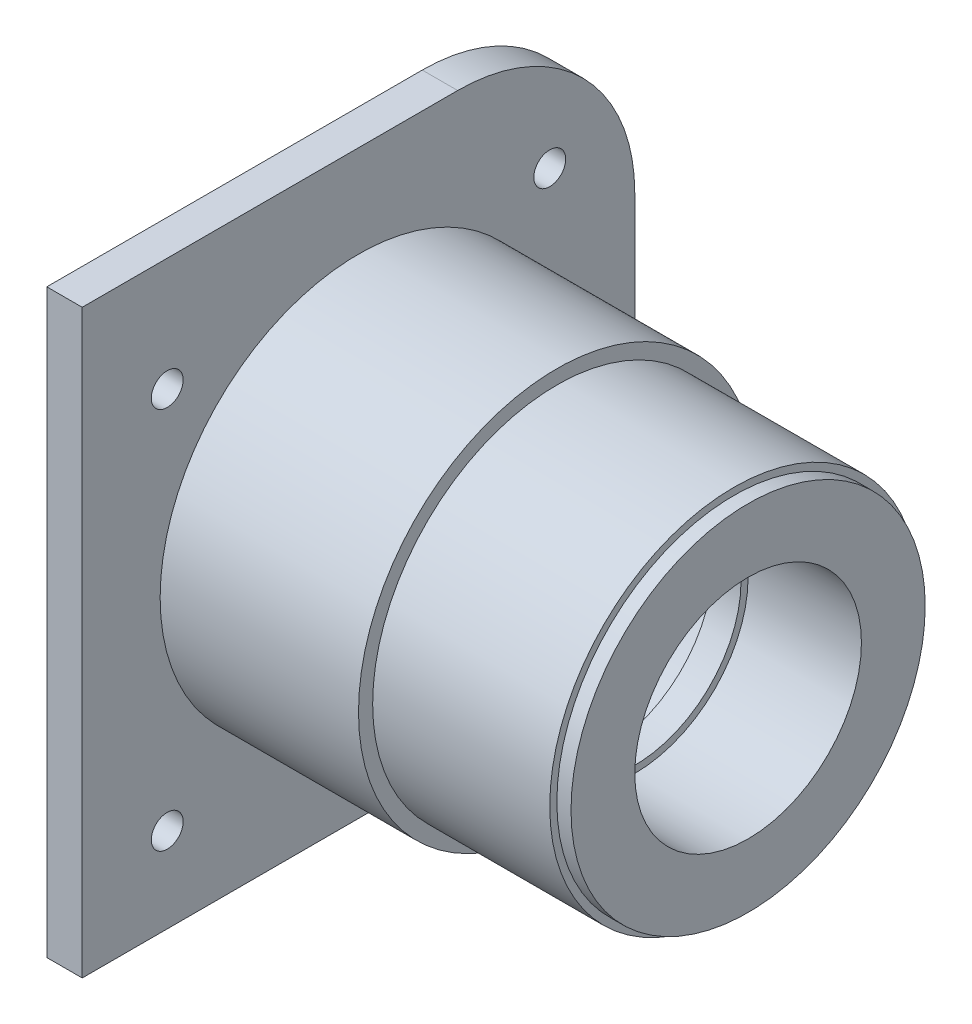
from build123d import *

# Parameters (mm, degrees)
SKETCH3_R                = 27.5
SKETCH3_R_2              = 25
CUT_EXTRUDE1_DEPTH       = 2
SKETCH4_W                = 78
SKETCH4_H                = 82
SKETCH4_W_2              = 42
SKETCH4_H_2              = 42
BOSS_EXTRUDE1_DEPTH      = 5
M4_CLEARANCE_HOLE1_D     = 4.5
M4_CLEARANCE_HOLE1_DEPTH = 5
BOSS_EXTRUDE4_DEPTH      = 5
FILLET1_R                = 25


with BuildPart() as part:
    # Sketch2 → Revolve1 (revolve)
    with BuildSketch(Plane.XY):
        Polygon((0, 21), (35, 21), (35, 15), (39, 15), (39, 16), (55, 16), (55, 26), (28, 26), (28, 28), (0, 28), align=None)
    revolve(axis=Axis((-64.103352454, 0, 0), (1, 0, 0)))

    # Sketch3 → Cut-Extrude1 (cut)
    with BuildSketch(Plane(origin=(53, 0, 0), x_dir=(0, 0, -1), z_dir=(1, 0, 0))):
        Circle(SKETCH3_R)
        Circle(SKETCH3_R_2, mode=Mode.SUBTRACT)
    extrude(amount=CUT_EXTRUDE1_DEPTH, mode=Mode.SUBTRACT)

    # Sketch4 → Boss-Extrude1 (add)
    with BuildSketch(Plane.ZY):
        Rectangle(SKETCH4_W, SKETCH4_H)
        Rectangle(SKETCH4_W_2, SKETCH4_H_2, mode=Mode.SUBTRACT)
    extrude(amount=BOSS_EXTRUDE1_DEPTH)

    # M4 Clearance Hole1
    with Locations(Plane.ZY.offset(5)):
        with Locations((-27, 25), (27, 25), (27, -29), (-27, -29)):
            Hole(M4_CLEARANCE_HOLE1_D / 2, depth=M4_CLEARANCE_HOLE1_DEPTH)

    # Sketch11 → Boss-Extrude4 (add)
    with BuildSketch(Plane.ZY):
        Polygon((-21, 18), (-18, 21), (-21, 21), align=None)
        Polygon((21, 21), (21, 18), (18, 21), align=None)
        Polygon((21, -21), (21, -18), (18, -21), align=None)
        Polygon((-21, -21), (-21, -18), (-18, -21), align=None)
    extrude(amount=BOSS_EXTRUDE4_DEPTH)

    # Fillet1
    fillet1_edges = [part.edges().sort_by_distance(p)[0] for p in [
        (-2.5, 41, -39),
        (-2.5, -41, -39),
    ]]
    fillet(fillet1_edges, radius=FILLET1_R)


solid = part.part
